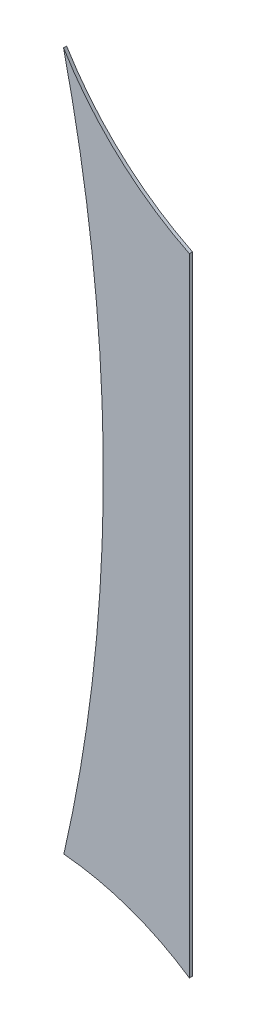
from build123d import *

# Parameters (mm, degrees)
SALIENTE_EXTRUIR1_DEPTH = 0.1


with BuildPart() as part:
    # Model → Saliente-Extruir1 (new body)
    with BuildSketch(Plane.XY):
        with BuildLine():
            ThreePointArc((17.084405856, -6.229220555), (19.197587735, -6.688514617), (21.127924111, -7.663342894))
            Line((21.127924111, -7.663342894), (21.12600502, 12.539738906))
            ThreePointArc((21.12600502, 12.539738906), (18.838024904, 14.111522879), (17.073556452, 16.254420205))
            ThreePointArc((17.073556452, 16.254420205), (18.355771059, 5.013215936), (17.084405856, -6.229220555))
        make_face()
    extrude(amount=SALIENTE_EXTRUIR1_DEPTH)


solid = part.part
